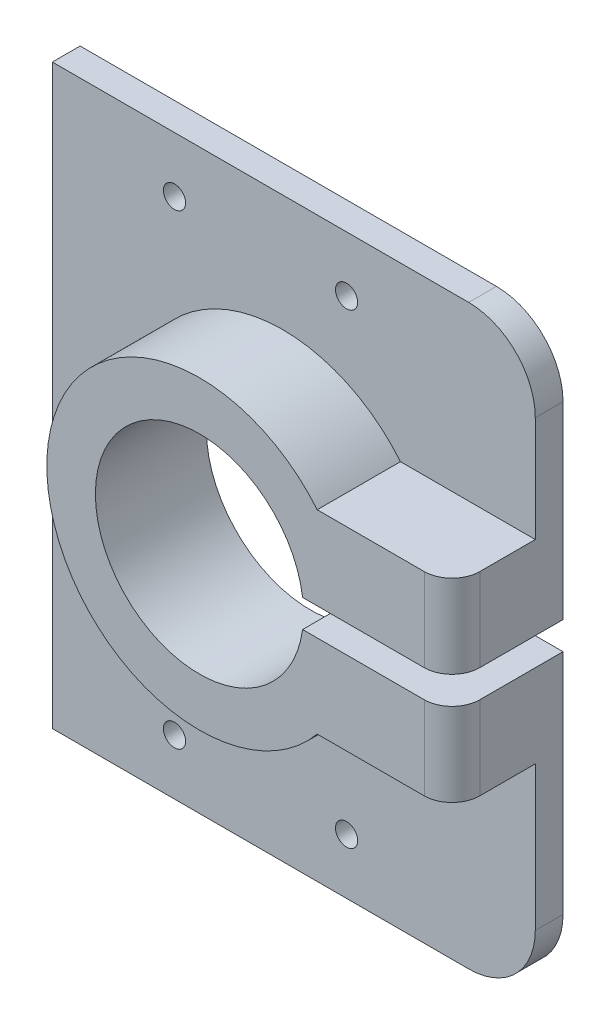
from build123d import *

# Parameters (mm, degrees)
SKETCH1_R           = 2
BOSS_EXTRUDE1_DEPTH = 5
BOSS_EXTRUDE2_DEPTH = 20
FILLET1_R           = 5


with BuildPart() as part:
    # Sketch1 → Boss-Extrude1 (new body)
    with BuildSketch(Plane.XY):
        with BuildLine():
            ThreePointArc((43.5, 40), (39.985281374, 48.485281374), (31.5, 52))
            Line((31.5, 52), (-43.5, 52))
            Line((-43.5, 52), (-43.5, -52))
            Line((-43.5, -52), (31.5, -52))
            ThreePointArc((31.5, -52), (39.985281374, -48.485281374), (43.5, -40))
            Line((43.5, -40), (43.5, -14.000000209))
            Line((43.5, -14.000000209), (39.5, -14.000000209))
            Line((39.5, -14.000000209), (19.213203263, -14.000000209))
            ThreePointArc((19.213203263, -14.000000209), (-29.5, 3.499999932), (19.213203177, 21.000000313))
            Line((19.213203177, 21.000000313), (39.5, 21.000000313))
            Line((39.5, 21.000000313), (43.5, 21.000000313))
            Line((43.5, 21.000000313), (43.5, 40))
        make_face()
        with Locations((-21.5, -42)):
            Circle(SKETCH1_R, mode=Mode.SUBTRACT)
        with Locations((9.5, -42)):
            Circle(SKETCH1_R, mode=Mode.SUBTRACT)
        with Locations((-21.5, 42)):
            Circle(SKETCH1_R, mode=Mode.SUBTRACT)
        with Locations((9.5, 42)):
            Circle(SKETCH1_R, mode=Mode.SUBTRACT)
    extrude(amount=BOSS_EXTRUDE1_DEPTH)

    # Sketch1_3 → Boss-Extrude2 (add)
    with BuildSketch(Plane.XY):
        with BuildLine():
            Line((43.5, 6), (43.5, 21.000000313))
            Line((43.5, 21.000000313), (39.5, 21.000000313))
            Line((39.5, 21.000000313), (19.213203177, 21.000000313))
            ThreePointArc((19.213203177, 21.000000313), (-29.5, 3.499999932), (19.213203263, -14.000000209))
            Line((19.213203263, -14.000000209), (39.5, -14.000000209))
            Line((39.5, -14.000000209), (43.5, -14.000000209))
            Line((43.5, -14.000000209), (43.5, 1))
            Line((43.5, 1), (39.5, 1))
            Line((39.5, 1), (16.582585934, 1))
            ThreePointArc((16.582585934, 1), (-20.75, 3.5), (16.582585934, 6))
            Line((16.582585934, 6), (39.5, 6))
            Line((39.5, 6), (43.5, 6))
        make_face()
    extrude(amount=BOSS_EXTRUDE2_DEPTH)

    # Fillet1
    fillet1_edges = [part.edges().sort_by_distance(p)[0] for p in [
        (43.5, -6.500000104, 20),
        (43.5, 13.500000156, 20),
    ]]
    fillet(fillet1_edges, radius=FILLET1_R)


solid = part.part
